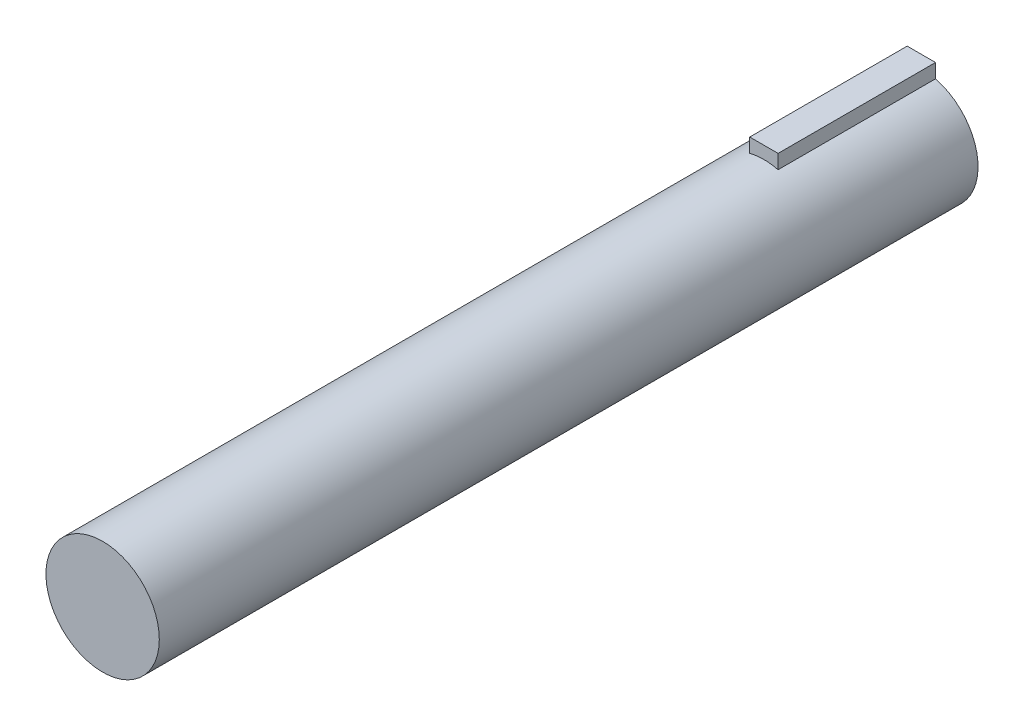
from build123d import *

# Parameters (mm, degrees)
SKETCH1_R           = 4.572
BOSS_EXTRUDE1_DEPTH = 66.04
SKETCH3_W           = 2.286
SKETCH3_H           = 2.286
BOSS_EXTRUDE3_DEPTH = 12.7


with BuildPart() as part:
    # Sketch1 → Boss-Extrude1 (new body)
    with BuildSketch(Plane.XY):
        Circle(SKETCH1_R)
    extrude(amount=BOSS_EXTRUDE1_DEPTH)

    # Sketch3 → Boss-Extrude3 (add)
    with BuildSketch(Plane(origin=(0, 0, 0), x_dir=(-1, 0, 0), z_dir=(0, 0, -1))):
        with Locations((0, 4.426819965)):
            Rectangle(SKETCH3_W, SKETCH3_H)
    extrude(amount=-BOSS_EXTRUDE3_DEPTH)


solid = part.part
